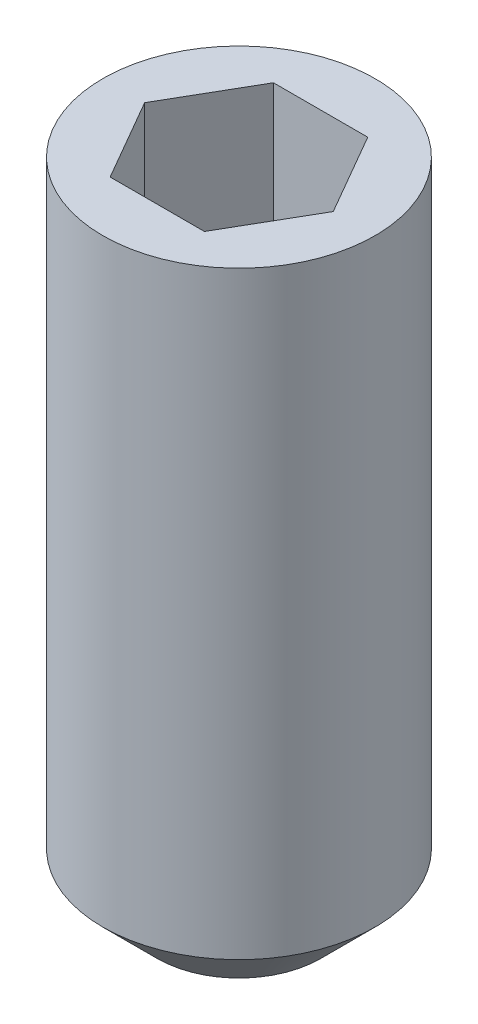
from build123d import *

# Parameters (mm, degrees)
SKETCH1_R           = 1.25
BOSS_EXTRUDE1_DEPTH = 6
CHAMFER1_SIZE       = 0.5
CUT_EXTRUDE1_DEPTH  = 1.5


with BuildPart() as part:
    # Sketch1 → Boss-Extrude1 (new body)
    with BuildSketch(Plane(origin=(0, 0, 0), x_dir=(1, 0, 0), z_dir=(0, 1, 0))):
        Circle(SKETCH1_R)
    extrude(amount=BOSS_EXTRUDE1_DEPTH)

    # Chamfer1
    chamfer1_edges = [part.edges().sort_by_distance(p)[0] for p in [
        (-1.25, 0, 0),
    ]]
    chamfer(chamfer1_edges, length=CHAMFER1_SIZE)

    # Sketch2 → Cut-Extrude1 (cut)
    with BuildSketch(Plane(origin=(0, 6, 0), x_dir=(1, 0, 0), z_dir=(0, 1, 0))):
        Polygon((0.433012702, -0.75), (0.866025404, 0), (0.433012702, 0.75), (-0.433012702, 0.75), (-0.866025404, 0), (-0.433012702, -0.75), align=None)
    extrude(amount=-CUT_EXTRUDE1_DEPTH, mode=Mode.SUBTRACT)


solid = part.part
